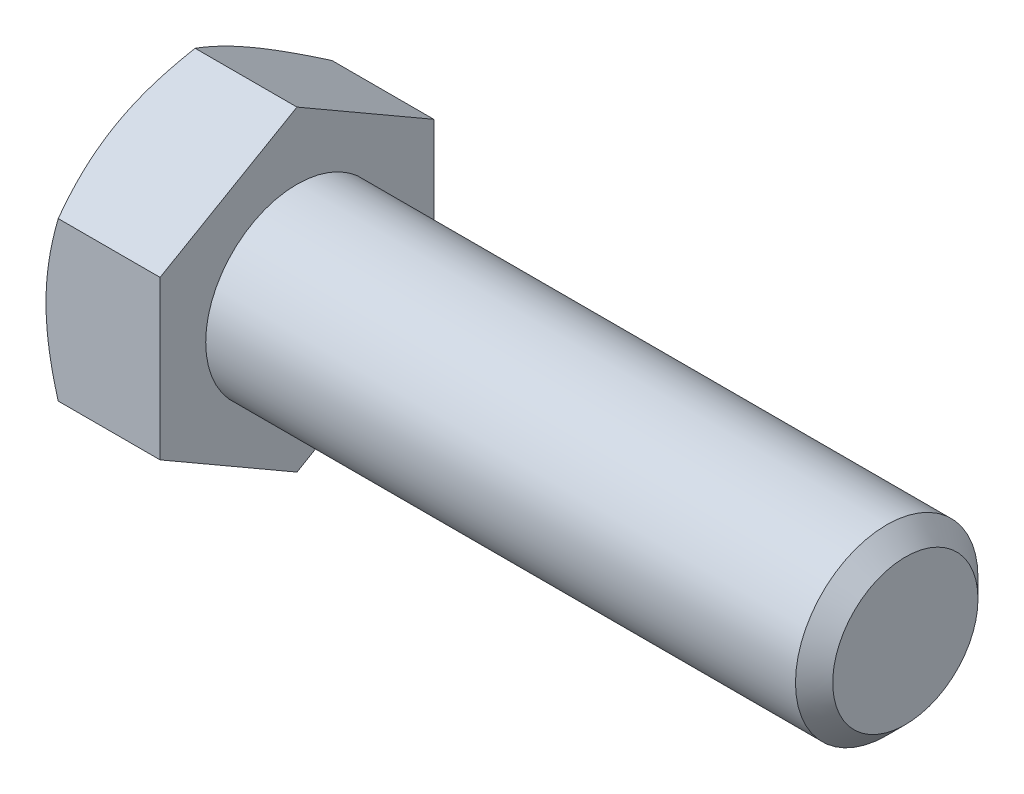
from build123d import *

# Parameters (mm, degrees)
SKETCH5_R           = 4.7625
BOSS_EXTRUDE3_DEPTH = 31.75
CHAMFER1_SIZE       = 0.97155
BOSS_EXTRUDE4_DEPTH = 5.953125
SKETCH8_OUTSIDE_W   = 159.072
SKETCH8_OUTSIDE_H   = 161.282
SKETCH8_OUTSIDE_R   = 7.14375
CUT_EXTRUDE3_DEPTH  = 38.703125
CUT_EXTRUDE3_TAPER  = 60
CUT_EXTRUDE4_DEPTH  = 0.254
CIRPATTERN1_COUNT   = 3


with BuildPart() as part:
    # Sketch5 → Boss-Extrude3 (new body)
    with BuildSketch(Plane(origin=(18.8515625, 0, 0), x_dir=(0, 0, -1), z_dir=(1, 0, 0))):
        Circle(SKETCH5_R)
    extrude(amount=-BOSS_EXTRUDE3_DEPTH)

    # Chamfer1
    chamfer1_edges = [part.edges().sort_by_distance(p)[0] for p in [
        (18.8515625, 0, 4.7625),
    ]]
    chamfer(chamfer1_edges, length=CHAMFER1_SIZE)

    # Sketch6 → Boss-Extrude4 (add)
    with BuildSketch(Plane.ZY.offset(12.8984375)):
        Polygon((7.14375, 4.124445986), (0, 8.248891971), (-7.14375, 4.124445986), (-7.14375, -4.124445986), (0, -8.248891971), (7.14375, -4.124445986), align=None)
    extrude(amount=BOSS_EXTRUDE4_DEPTH)

    # Sketch8 outside → Cut-Extrude3 (cut, through all)
    with BuildSketch(Plane.ZY.offset(18.8515625)):
        Rectangle(SKETCH8_OUTSIDE_W, SKETCH8_OUTSIDE_H)
        Circle(SKETCH8_OUTSIDE_R, mode=Mode.SUBTRACT)
    extrude(amount=-CUT_EXTRUDE3_DEPTH, taper=CUT_EXTRUDE3_TAPER, mode=Mode.SUBTRACT)

    # Sketch12 → Cut-Extrude4 (cut)
    with BuildSketch(Plane.ZY.offset(18.8515625)):
        with BuildLine():
            Line((0.2143125, 5.5006875), (0.2143125, 3.0718125))
            ThreePointArc((0.2143125, 3.0718125), (0, 2.8575), (-0.2143125, 3.0718125))
            Line((-0.2143125, 3.0718125), (-0.2143125, 5.5006875))
            ThreePointArc((-0.2143125, 5.5006875), (0, 5.715), (0.2143125, 5.5006875))
        make_face()
    cut_extrude4 = extrude(amount=-CUT_EXTRUDE4_DEPTH, mode=Mode.SUBTRACT)

    # CirPattern1: Cut-Extrude4 ×3 about axis
    cirpattern1_axis = Axis((0, 0, 0), (1, 0, 0))
    for i in range(1, CIRPATTERN1_COUNT):
        add(cut_extrude4.rotate(cirpattern1_axis, i * 360 / CIRPATTERN1_COUNT), mode=Mode.SUBTRACT)


solid = part.part
